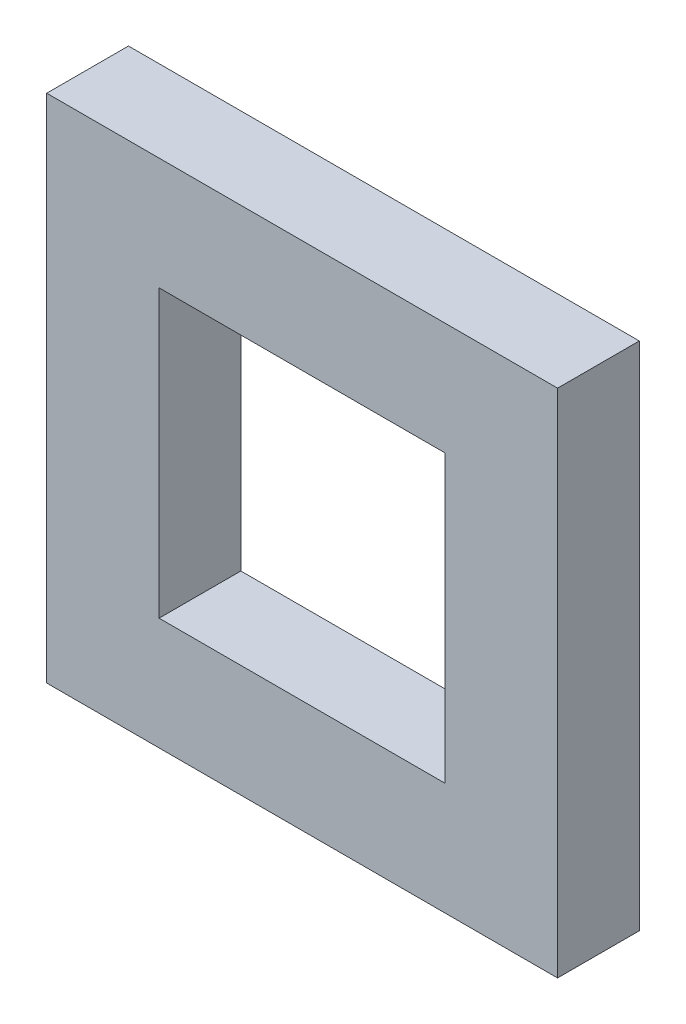
from build123d import *

# Parameters (mm, degrees)
SKETCH1_W           = 635
SKETCH1_H           = 635
BOSS_EXTRUDE1_DEPTH = 101.6
SKETCH2_W           = 355.6
SKETCH2_H           = 355.6
CUT_EXTRUDE1_DEPTH  = 101.6


with BuildPart() as part:
    # Sketch1 → Boss-Extrude1 (new body)
    with BuildSketch(Plane.XY):
        Rectangle(SKETCH1_W, SKETCH1_H)
    extrude(amount=BOSS_EXTRUDE1_DEPTH)

    # Sketch2 → Cut-Extrude1 (cut)
    with BuildSketch(Plane.XY.offset(101.6)):
        Rectangle(SKETCH2_W, SKETCH2_H)
    extrude(amount=-CUT_EXTRUDE1_DEPTH, mode=Mode.SUBTRACT)


solid = part.part
